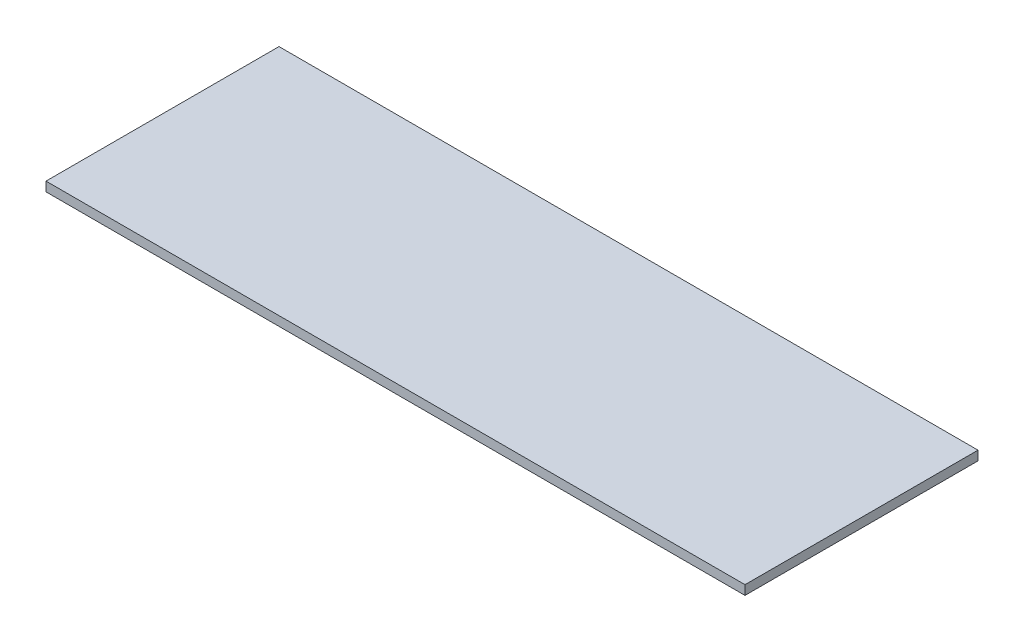
from build123d import *

# Parameters (mm, degrees)
SKETCH1_W           = 75
SKETCH1_H           = 25
BOSS_EXTRUDE1_DEPTH = 1


with BuildPart() as part:
    # Sketch1 → Boss-Extrude1 (new body)
    with BuildSketch(Plane(origin=(0, 0, 0), x_dir=(1, 0, 0), z_dir=(0, 1, 0))):
        with Locations((37.5, 12.5)):
            Rectangle(SKETCH1_W, SKETCH1_H)
    extrude(amount=BOSS_EXTRUDE1_DEPTH)


solid = part.part
